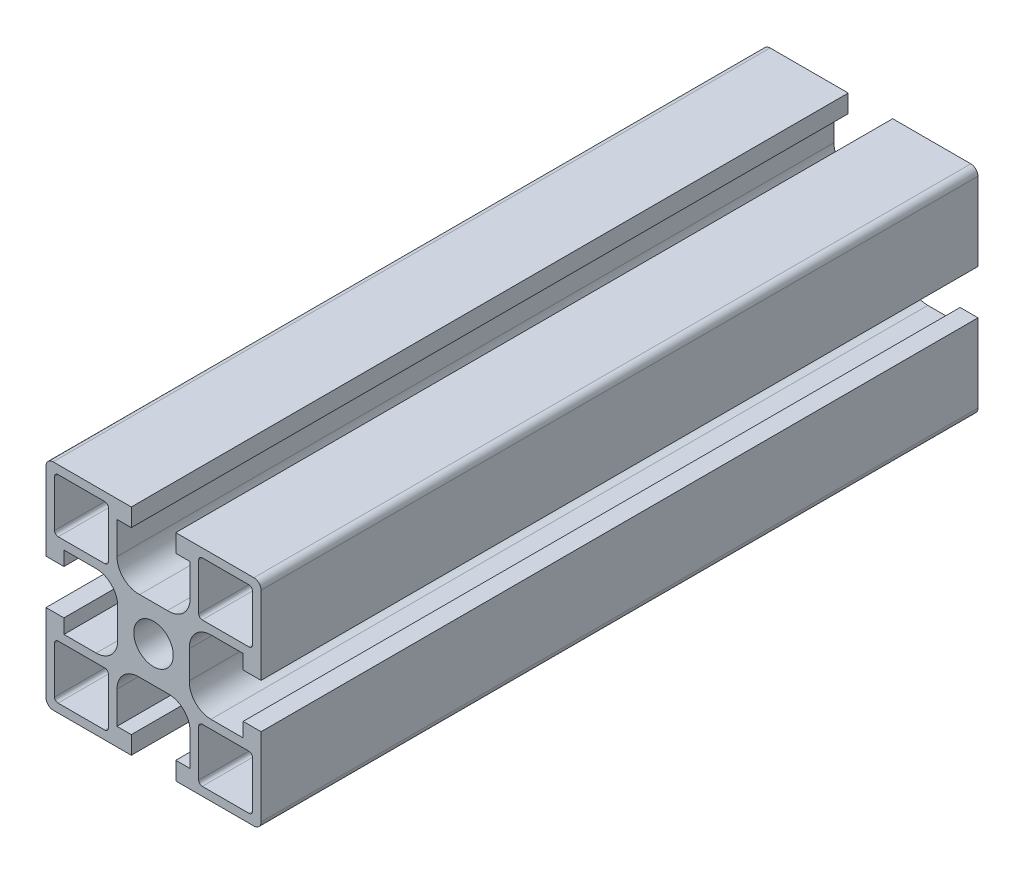
from build123d import *

# Parameters (mm, degrees)
SKETCH1_6_R         = 2.75
BOSS_EXTRUDE3_DEPTH = 100


with BuildPart() as part:
    # Sketch1_6 → Boss-Extrude3 (new body)
    with BuildSketch(Plane.XY):
        with BuildLine():
            Line((-8.207857566, 15.784975365), (-8.207857566, 13.784975365))
            Line((-8.207857566, 13.784975365), (-5.707857566, 13.784975365))
            Line((-5.707857566, 13.784975365), (-5.707857566, 24.684975365))
            ThreePointArc((-5.707857566, 24.684975365), (-6.000750784, 25.392082146), (-6.707857566, 25.684975365))
            Line((-6.707857566, 25.684975365), (-17.607857566, 25.684975365))
            Line((-17.607857566, 25.684975365), (-17.607857566, 23.184975365))
            Line((-17.607857566, 23.184975365), (-15.607857566, 23.184975365))
            Line((-15.607857566, 23.184975365), (-15.607857566, 18.878818393))
            Line((-15.607857566, 18.878818393), (-15.607857566, 18.684975365))
            ThreePointArc((-15.607857566, 18.684975365), (-16.432542315, 16.617397323), (-18.453822402, 15.684975365))
            ThreePointArc((-18.453822402, 15.684975365), (-18.61202607, 15.680806861), (-18.770229737, 15.684975365))
            Line((-18.770229737, 15.684975365), (-22.645485394, 15.684975365))
            ThreePointArc((-22.645485394, 15.684975365), (-22.803689062, 15.680806861), (-22.961892729, 15.684975365))
            ThreePointArc((-22.961892729, 15.684975365), (-24.983172816, 16.617397323), (-25.807857566, 18.684975365))
            Line((-25.807857566, 18.684975365), (-25.807857566, 18.878818393))
            Line((-25.807857566, 18.878818393), (-25.807857566, 23.184975365))
            Line((-25.807857566, 23.184975365), (-23.807857566, 23.184975365))
            Line((-23.807857566, 23.184975365), (-23.807857566, 25.684975365))
            Line((-23.807857566, 25.684975365), (-34.707857566, 25.684975365))
            ThreePointArc((-34.707857566, 25.684975365), (-35.414964347, 25.392082146), (-35.707857566, 24.684975365))
            Line((-35.707857566, 24.684975365), (-35.707857566, 13.784975365))
            Line((-35.707857566, 13.784975365), (-33.207857566, 13.784975365))
            Line((-33.207857566, 13.784975365), (-33.207857566, 15.784975365))
            Line((-33.207857566, 15.784975365), (-28.901700593, 15.784975365))
            Line((-28.901700593, 15.784975365), (-28.707857566, 15.784975365))
            ThreePointArc((-28.707857566, 15.784975365), (-26.640279523, 14.960290616), (-25.707857566, 12.939010529))
            ThreePointArc((-25.707857566, 12.939010529), (-25.703689062, 12.780806861), (-25.707857566, 12.622603193))
            Line((-25.707857566, 12.622603193), (-25.707857566, 8.747347537))
            ThreePointArc((-25.707857566, 8.747347537), (-25.703689062, 8.589143869), (-25.707857566, 8.430940201))
            ThreePointArc((-25.707857566, 8.430940201), (-26.640279523, 6.409660114), (-28.707857566, 5.584975365))
            Line((-28.707857566, 5.584975365), (-28.901700593, 5.584975365))
            Line((-28.901700593, 5.584975365), (-33.207857566, 5.584975365))
            Line((-33.207857566, 5.584975365), (-33.207857566, 7.584975365))
            Line((-33.207857566, 7.584975365), (-35.707857566, 7.584975365))
            Line((-35.707857566, 7.584975365), (-35.707857566, -3.315024635))
            ThreePointArc((-35.707857566, -3.315024635), (-35.414964347, -4.022131416), (-34.707857566, -4.315024635))
            Line((-34.707857566, -4.315024635), (-23.807857566, -4.315024635))
            Line((-23.807857566, -4.315024635), (-23.807857566, -1.815024635))
            Line((-23.807857566, -1.815024635), (-25.807857566, -1.815024635))
            Line((-25.807857566, -1.815024635), (-25.807857566, 2.491132338))
            Line((-25.807857566, 2.491132338), (-25.807857566, 2.684975365))
            ThreePointArc((-25.807857566, 2.684975365), (-24.983172816, 4.752553408), (-22.961892729, 5.684975365))
            ThreePointArc((-22.961892729, 5.684975365), (-22.803689062, 5.689143869), (-22.645485394, 5.684975365))
            Line((-22.645485394, 5.684975365), (-18.770229737, 5.684975365))
            ThreePointArc((-18.770229737, 5.684975365), (-18.61202607, 5.689143869), (-18.453822402, 5.684975365))
            ThreePointArc((-18.453822402, 5.684975365), (-16.432542315, 4.752553408), (-15.607857566, 2.684975365))
            Line((-15.607857566, 2.684975365), (-15.607857566, 2.491132338))
            Line((-15.607857566, 2.491132338), (-15.607857566, -1.815024635))
            Line((-15.607857566, -1.815024635), (-17.607857566, -1.815024635))
            Line((-17.607857566, -1.815024635), (-17.607857566, -4.315024635))
            Line((-17.607857566, -4.315024635), (-6.707857566, -4.315024635))
            ThreePointArc((-6.707857566, -4.315024635), (-6.000750784, -4.022131416), (-5.707857566, -3.315024635))
            Line((-5.707857566, -3.315024635), (-5.707857566, 7.584975365))
            Line((-5.707857566, 7.584975365), (-8.207857566, 7.584975365))
            Line((-8.207857566, 7.584975365), (-8.207857566, 5.584975365))
            Line((-8.207857566, 5.584975365), (-12.514014538, 5.584975365))
            Line((-12.514014538, 5.584975365), (-12.707857566, 5.584975365))
            ThreePointArc((-12.707857566, 5.584975365), (-14.775435608, 6.409660114), (-15.707857566, 8.430940201))
            ThreePointArc((-15.707857566, 8.430940201), (-15.71202607, 8.589143869), (-15.707857566, 8.747347537))
            Line((-15.707857566, 8.747347537), (-15.707857566, 12.622603193))
            ThreePointArc((-15.707857566, 12.622603193), (-15.71202607, 12.780806861), (-15.707857566, 12.939010529))
            ThreePointArc((-15.707857566, 12.939010529), (-14.775435608, 14.960290616), (-12.707857566, 15.784975365))
            Line((-12.707857566, 15.784975365), (-12.514014538, 15.784975365))
            Line((-12.514014538, 15.784975365), (-8.207857566, 15.784975365))
        make_face()
        with BuildLine():
            Line((-34.507857566, -2.63034887), (-34.507857566, 3.884975365))
            ThreePointArc((-34.507857566, 3.884975365), (-34.361410956, 4.238528756), (-34.007857566, 4.384975365))
            Line((-34.007857566, 4.384975365), (-27.507857566, 4.384975365))
            ThreePointArc((-27.507857566, 4.384975365), (-27.154304175, 4.238528756), (-27.007857566, 3.884975365))
            Line((-27.007857566, 3.884975365), (-27.007857566, -2.615024635))
            ThreePointArc((-27.007857566, -2.615024635), (-27.154304175, -2.968578025), (-27.507857566, -3.115024635))
            Line((-27.507857566, -3.115024635), (-34.023181801, -3.115024635))
            ThreePointArc((-34.023181801, -3.115024635), (-34.365899321, -2.97306639), (-34.507857566, -2.63034887))
        make_face(mode=Mode.SUBTRACT)
        with BuildLine():
            Line((-7.39253333, -3.115024635), (-13.907857566, -3.115024635))
            ThreePointArc((-13.907857566, -3.115024635), (-14.261410956, -2.968578025), (-14.407857566, -2.615024635))
            Line((-14.407857566, -2.615024635), (-14.407857566, 3.884975365))
            ThreePointArc((-14.407857566, 3.884975365), (-14.261410956, 4.238528756), (-13.907857566, 4.384975365))
            Line((-13.907857566, 4.384975365), (-7.407857566, 4.384975365))
            ThreePointArc((-7.407857566, 4.384975365), (-7.054304175, 4.238528756), (-6.907857566, 3.884975365))
            Line((-6.907857566, 3.884975365), (-6.907857566, -2.63034887))
            ThreePointArc((-6.907857566, -2.63034887), (-7.04981581, -2.97306639), (-7.39253333, -3.115024635))
        make_face(mode=Mode.SUBTRACT)
        with BuildLine():
            Line((-34.023181801, 24.484975365), (-27.507857566, 24.484975365))
            ThreePointArc((-27.507857566, 24.484975365), (-27.154304175, 24.338528756), (-27.007857566, 23.984975365))
            Line((-27.007857566, 23.984975365), (-27.007857566, 17.484975365))
            ThreePointArc((-27.007857566, 17.484975365), (-27.154304175, 17.131421975), (-27.507857566, 16.984975365))
            Line((-27.507857566, 16.984975365), (-34.007857566, 16.984975365))
            ThreePointArc((-34.007857566, 16.984975365), (-34.361410956, 17.131421975), (-34.507857566, 17.484975365))
            Line((-34.507857566, 17.484975365), (-34.507857566, 24.000299601))
            ThreePointArc((-34.507857566, 24.000299601), (-34.365899321, 24.34301712), (-34.023181801, 24.484975365))
        make_face(mode=Mode.SUBTRACT)
        with Locations((-20.707857566, 10.684975365)):
            Circle(SKETCH1_6_R, mode=Mode.SUBTRACT)
        with BuildLine():
            Line((-6.907857566, 24.000299601), (-6.907857566, 17.484975365))
            ThreePointArc((-6.907857566, 17.484975365), (-7.054304175, 17.131421975), (-7.407857566, 16.984975365))
            Line((-7.407857566, 16.984975365), (-13.907857566, 16.984975365))
            ThreePointArc((-13.907857566, 16.984975365), (-14.261410956, 17.131421975), (-14.407857566, 17.484975365))
            Line((-14.407857566, 17.484975365), (-14.407857566, 23.984975365))
            ThreePointArc((-14.407857566, 23.984975365), (-14.261410956, 24.338528756), (-13.907857566, 24.484975365))
            Line((-13.907857566, 24.484975365), (-7.39253333, 24.484975365))
            ThreePointArc((-7.39253333, 24.484975365), (-7.04981581, 24.34301712), (-6.907857566, 24.000299601))
        make_face(mode=Mode.SUBTRACT)
    extrude(amount=BOSS_EXTRUDE3_DEPTH)


solid = part.part
